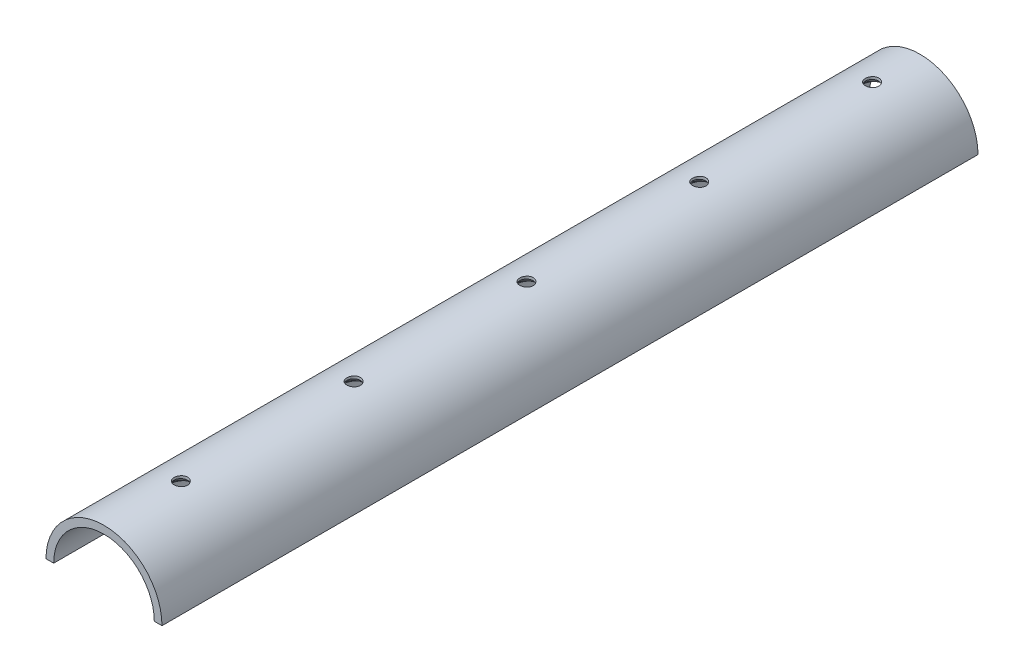
from build123d import *

# Parameters (mm, degrees)
SKETCH2_R                                      = 30.2
BOSS_EXTRUDE1_DEPTH                            = 425
SKETCH3_R                                      = 26.2
CUT_EXTRUDE1_DEPTH                             = 426
CUT_EXTRUDE2_REACH                             = 32.2
SKETCH4_W                                      = 60.4
SKETCH4_H                                      = 425
CSK_FOR_M6_FLAT_HEAD_MACHINE_SCREW1_AT_2_COUNT = 2
CSK_FOR_M6_FLAT_HEAD_MACHINE_SCREW1_AT_2_PITCH = 90
CSK_FOR_M6_FLAT_HEAD_MACHINE_SCREW1_AT_3_COUNT = 2
CSK_FOR_M6_FLAT_HEAD_MACHINE_SCREW1_AT_3_PITCH = 180
CSK_FOR_M6_FLAT_HEAD_MACHINE_SCREW1_AT_4_COUNT = 2
CSK_FOR_M6_FLAT_HEAD_MACHINE_SCREW1_AT_4_PITCH = 270
CSK_FOR_M6_FLAT_HEAD_MACHINE_SCREW1_AT_5_COUNT = 2
CSK_FOR_M6_FLAT_HEAD_MACHINE_SCREW1_AT_5_PITCH = 360


with BuildPart() as part:
    # Sketch2 → Boss-Extrude1 (new body)
    with BuildSketch(Plane.XY):
        Circle(SKETCH2_R)
    extrude(amount=-BOSS_EXTRUDE1_DEPTH)

    # Sketch3 → Cut-Extrude1 (cut, through all)
    with BuildSketch(Plane.XY):
        Circle(SKETCH3_R)
    extrude(amount=-CUT_EXTRUDE1_DEPTH, mode=Mode.SUBTRACT)

    # Sketch4 → Cut-Extrude2 (cut, up to next)
    with BuildSketch(Plane(origin=(0, 0, 0), x_dir=(1, 0, 0), z_dir=(0, 1, 0)), mode=Mode.PRIVATE) as cut_extrude2_sk1:
        with Locations((0, 212.5)):
            Rectangle(SKETCH4_W, SKETCH4_H)
    cut_extrude2_tool1 = extrude(cut_extrude2_sk1.sketch, amount=-CUT_EXTRUDE2_REACH, mode=Mode.PRIVATE) & part.part
    add(cut_extrude2_tool1.solids().sort_by_distance((0, 0, -212.5))[0], mode=Mode.SUBTRACT)

    # Sketch10 → CSK for M6 Flat Head Machine Screw1 (revolve, cut)
    with BuildSketch(Plane(origin=(0, 0, -40), x_dir=(0, 0, -1), z_dir=(1, 0, 0))):
        Polygon((0, 0), (0, 30.2), (3.5, 30.2), (3.5, 28.8), (6.3, 26), (6.3, 0), align=None)
    csk_for_m6_flat_head_machine_screw1 = revolve(axis=Axis((0, -6.35, -40), (0, 1, 0)), mode=Mode.SUBTRACT)

    # CSK for M6 Flat Head Machine Screw1 at 2: CSK for M6 Flat Head Machine Screw1 ×2
    with Locations(*[(0, 0, -i * CSK_FOR_M6_FLAT_HEAD_MACHINE_SCREW1_AT_2_PITCH) for i in range(1, CSK_FOR_M6_FLAT_HEAD_MACHINE_SCREW1_AT_2_COUNT)]):
        add(csk_for_m6_flat_head_machine_screw1, mode=Mode.SUBTRACT)

    # CSK for M6 Flat Head Machine Screw1 at 3: CSK for M6 Flat Head Machine Screw1 ×2
    with Locations(*[(0, 0, -i * CSK_FOR_M6_FLAT_HEAD_MACHINE_SCREW1_AT_3_PITCH) for i in range(1, CSK_FOR_M6_FLAT_HEAD_MACHINE_SCREW1_AT_3_COUNT)]):
        add(csk_for_m6_flat_head_machine_screw1, mode=Mode.SUBTRACT)

    # CSK for M6 Flat Head Machine Screw1 at 4: CSK for M6 Flat Head Machine Screw1 ×2
    with Locations(*[(0, 0, -i * CSK_FOR_M6_FLAT_HEAD_MACHINE_SCREW1_AT_4_PITCH) for i in range(1, CSK_FOR_M6_FLAT_HEAD_MACHINE_SCREW1_AT_4_COUNT)]):
        add(csk_for_m6_flat_head_machine_screw1, mode=Mode.SUBTRACT)

    # CSK for M6 Flat Head Machine Screw1 at 5: CSK for M6 Flat Head Machine Screw1 ×2
    with Locations(*[(0, 0, -i * CSK_FOR_M6_FLAT_HEAD_MACHINE_SCREW1_AT_5_PITCH) for i in range(1, CSK_FOR_M6_FLAT_HEAD_MACHINE_SCREW1_AT_5_COUNT)]):
        add(csk_for_m6_flat_head_machine_screw1, mode=Mode.SUBTRACT)


solid = part.part
